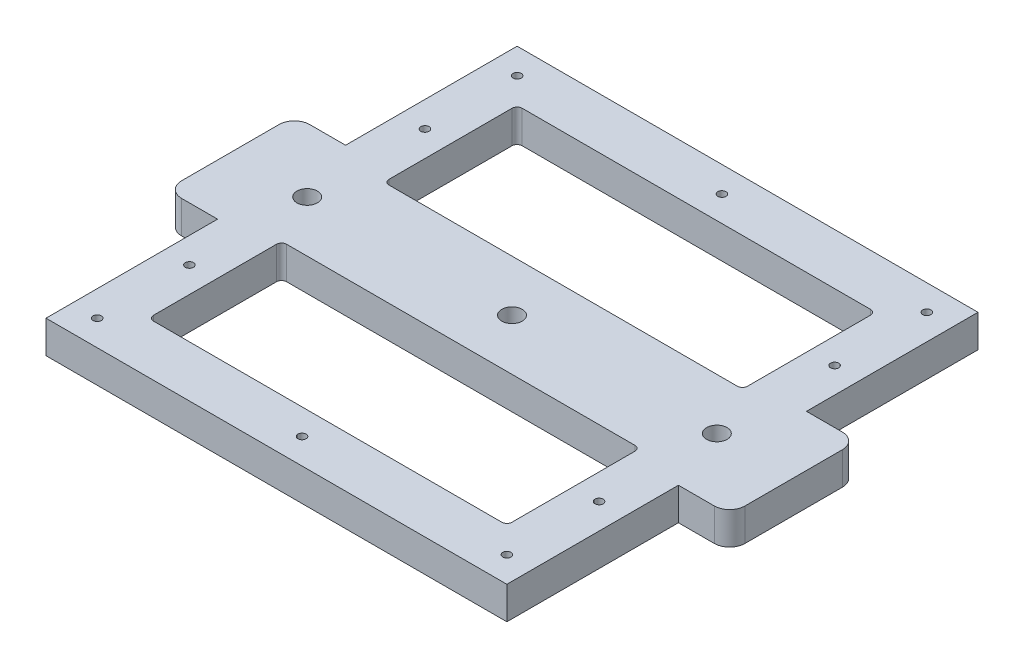
from build123d import *

# Parameters (mm, degrees)
BOSS_EXTRUDE1_DEPTH         = 6.35
FILLET1_R                   = 1
TAP_DRILL_FOR_M2X0_4_TAP1_D = 1.6
SKETCH7_R                   = 0.8
CUT_EXTRUDE1_DEPTH          = 7.35
FILLET1_OF_MIRROR1_R        = 1
SKETCH6_W                   = 25
SKETCH6_H                   = 6.35
BOSS_EXTRUDE2_DEPTH         = 10
FILLET2_R                   = 3
FILLET2_OF_MIRROR2_R        = 3
SKETCH8_R                   = 2
CUT_EXTRUDE2_DEPTH          = 10


with BuildPart() as part:
    # Sketch1 → Boss-Extrude1 (new body)
    with BuildSketch(Plane(origin=(0, 0, 0), x_dir=(1, 0, 0), z_dir=(0, 1, 0))):
        Polygon((10, 10), (10, 36), (0, 46), (0, 0), align=None)
        Polygon((10, 36), (80, 36), (90, 46), (0, 46), align=None)
        Polygon((80, 10), (90, 0), (0, 0), (10, 10), align=None)
        Polygon((80, 10), (80, 36), (90, 46), (90, 0), align=None)
    boss_extrude1 = extrude(amount=BOSS_EXTRUDE1_DEPTH)

    # Fillet1
    fillet1_edges = [part.edges().sort_by_distance(p)[0] for p in [
        (10, 3.175, -10),
        (80, 3.175, -10),
        (80, 3.175, -36),
        (10, 3.175, -36),
    ]]
    fillet(fillet1_edges, radius=FILLET1_R)

    # Tap Drill for M2x0.4 Tap1 (through all)
    with Locations(Plane(origin=(0, 6.35, 0), x_dir=(1, 0, 0), z_dir=(0, 1, 0))):
        with Locations((85, 5), (5, 5)):
            tap_drill_for_m2x0_4_tap1 = Hole(TAP_DRILL_FOR_M2X0_4_TAP1_D / 2)

    # Sketch7 → Cut-Extrude1 (cut, through all)
    with BuildSketch(Plane(origin=(0, 6.35, 0), x_dir=(1, 0, 0), z_dir=(0, 1, 0))):
        with Locations((85, 23)):
            Circle(SKETCH7_R)
        with Locations((45, 5)):
            Circle(SKETCH7_R)
        with Locations((5, 23)):
            Circle(SKETCH7_R)
    cut_extrude1 = extrude(amount=-CUT_EXTRUDE1_DEPTH, mode=Mode.SUBTRACT)

    # Mirror1: Boss-Extrude1, Tap Drill for M2x0.4 Tap1 across plane
    add(boss_extrude1.mirror(Plane(origin=(0, 0, -46), x_dir=(1, 0, 0), z_dir=(0, 0, -1))))
    add(tap_drill_for_m2x0_4_tap1.mirror(Plane(origin=(0, 0, -46), x_dir=(1, 0, 0), z_dir=(0, 0, -1))), mode=Mode.SUBTRACT)

    # Fillet1 of Mirror1
    fillet1_of_mirror1_edges = [part.edges().sort_by_distance(p)[0] for p in [
        (10, 3.175, -82),
        (80, 3.175, -82),
        (80, 3.175, -56),
        (10, 3.175, -56),
    ]]
    fillet(fillet1_of_mirror1_edges, radius=FILLET1_OF_MIRROR1_R)

    # Sketch6 → Boss-Extrude2 (add)
    with BuildSketch(Plane(origin=(90, 0, 0), x_dir=(0, 0, -1), z_dir=(1, 0, 0))):
        with Locations((46, 3.175)):
            Rectangle(SKETCH6_W, SKETCH6_H)
    boss_extrude2 = extrude(amount=BOSS_EXTRUDE2_DEPTH)

    # Fillet2
    fillet2_edges = [part.edges().sort_by_distance(p)[0] for p in [
        (100, 3.175, -58.5),
        (100, 3.175, -33.5),
    ]]
    fillet(fillet2_edges, radius=FILLET2_R)

    # Mirror2: Boss-Extrude2 across plane
    add(boss_extrude2.mirror(Plane.ZY.offset(-45)))

    # Fillet2 of Mirror2
    fillet2_of_mirror2_edges = [part.edges().sort_by_distance(p)[0] for p in [
        (-10, 3.175, -58.5),
        (-10, 3.175, -33.5),
    ]]
    fillet(fillet2_of_mirror2_edges, radius=FILLET2_OF_MIRROR2_R)

    # Mirror3: Cut-Extrude1 across plane
    add(cut_extrude1.mirror(Plane(origin=(0, 0, -46), x_dir=(1, 0, 0), z_dir=(0, 0, -1))), mode=Mode.SUBTRACT)

    # Sketch8 → Cut-Extrude2 (cut)
    with BuildSketch(Plane(origin=(0, 0, 0), x_dir=(-1, 0, 0), z_dir=(0, -1, 0))):
        with Locations((-45, 46)):
            Circle(SKETCH8_R)
        with Locations((-85, 46)):
            Circle(SKETCH8_R)
        with Locations((-5, 46)):
            Circle(SKETCH8_R)
    extrude(amount=-CUT_EXTRUDE2_DEPTH, mode=Mode.SUBTRACT)


solid = part.part
